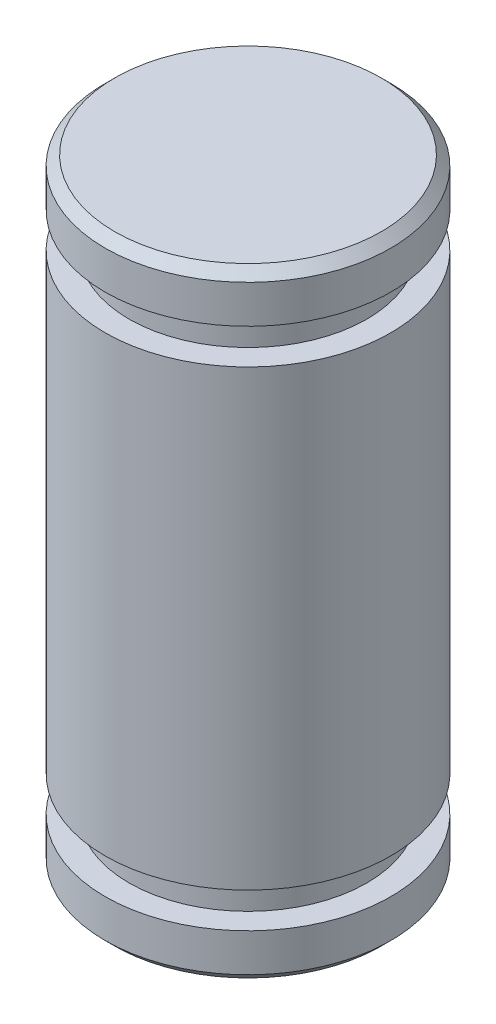
from build123d import *

# Parameters (mm, degrees)
SKETCH1_W       = 3
SKETCH1_H       = 13
SKETCH5_W       = 2.05
SKETCH5_H       = 0.74
CHANFREIN1_SIZE = 0.2


with BuildPart() as part:
    # Sketch1 → Revolve1 (revolve)
    with BuildSketch(Plane.XY):
        with Locations((1.5, 6.5)):
            Rectangle(SKETCH1_W, SKETCH1_H)
    revolve(axis=Axis((0, 0, 0), (0, 1, 0)))

    # Sketch5 → Groove for DIN 471 - 4 x 0.4, Circlip for shafts - normal1 (revolve, cut)
    with BuildSketch(Plane(origin=(0, 0, 0), x_dir=(0, 0, -1), z_dir=(-1, 0, 0))):
        with Locations((3.525, -1.37)):
            Rectangle(SKETCH5_W, SKETCH5_H)
        with Locations((3.525, -11.63)):
            Rectangle(SKETCH5_W, SKETCH5_H)
    revolve(axis=Axis((0, 50.028808754, 0), (0, -1, 0)), mode=Mode.SUBTRACT)

    # Chanfrein1
    chanfrein1_edges = [part.edges().sort_by_distance(p)[0] for p in [
        (-3, 0, 0),
        (-3, 13, 0),
    ]]
    chamfer(chanfrein1_edges, length=CHANFREIN1_SIZE)


solid = part.part
